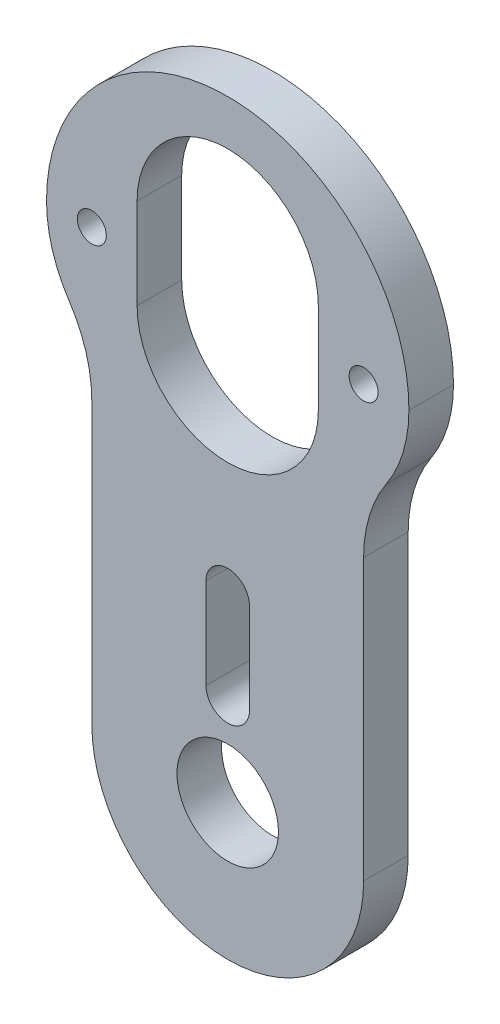
from build123d import *

# Parameters (mm, degrees)
CROQUIS1_R              = 3.556
SALIENTE_EXTRUIR1_DEPTH = 3.1242
SALIENTE_EXTRUIR3_START = -3.1242
SALIENTE_EXTRUIR3_DEPTH = 3.1242
CROQUIS3_R              = 1.016
CORTAR_EXTRUIR1_DEPTH   = 45.81344142


with BuildPart() as part:
    # Croquis1 → Saliente-Extruir1 (new body)
    with BuildSketch(Plane.XY):
        with BuildLine():
            Line((9.525, 0), (9.525, 33.3375))
            ThreePointArc((9.525, 33.3375), (0, 42.8625), (-9.525, 33.3375))
            Line((-9.525, 33.3375), (-9.525, 0))
            ThreePointArc((-9.525, 0), (0, -9.525), (9.525, 0))
        make_face()
        Circle(CROQUIS1_R, mode=Mode.SUBTRACT)
        with BuildLine():
            ThreePointArc((-6.35, 26.9875), (0, 20.6375), (6.35, 26.9875))
            Line((6.35, 26.9875), (6.35, 33.3375))
            ThreePointArc((6.35, 33.3375), (0, 39.6875), (-6.35, 33.3375))
            Line((-6.35, 33.3375), (-6.35, 26.9875))
        make_face(mode=Mode.SUBTRACT)
        with BuildLine():
            ThreePointArc((1.524, 12.7), (0, 14.224), (-1.524, 12.7))
            Line((-1.524, 12.7), (-1.524, 6.35))
            ThreePointArc((-1.524, 6.35), (0, 4.826), (1.524, 6.35))
            Line((1.524, 6.35), (1.524, 12.7))
        make_face(mode=Mode.SUBTRACT)
    extrude(amount=SALIENTE_EXTRUIR1_DEPTH)

    # Croquis2 → Saliente-Extruir3 (add)
    with BuildSketch(Plane.XY.offset(3.1242).offset(SALIENTE_EXTRUIR3_START)):
        with BuildLine():
            ThreePointArc((-9.525, 33.3375), (-6.735192091, 40.072692091), (0, 42.8625))
            ThreePointArc((0, 42.8625), (-8.980256121, 39.142756121), (-12.7, 30.1625))
            ThreePointArc((-12.7, 30.1625), (-12.294493201, 27.412869343), (-11.1125, 24.897358145))
            ThreePointArc((-11.1125, 24.897358145), (-9.930506799, 22.381846948), (-9.525, 19.632216291))
            Line((-9.525, 19.632216291), (-9.525, 29.1465))
            ThreePointArc((-9.525, 29.1465), (-10.541, 30.1625), (-9.525, 31.1785))
            Line((-9.525, 31.1785), (-9.525, 33.3375))
        make_face()
        with BuildLine():
            ThreePointArc((12.7, 30.1625), (8.980256121, 39.142756121), (0, 42.8625))
            ThreePointArc((0, 42.8625), (6.735192091, 40.072692091), (9.525, 33.3375))
            Line((9.525, 33.3375), (9.525, 31.1785))
            ThreePointArc((9.525, 31.1785), (10.541, 30.1625), (9.525, 29.1465))
            Line((9.525, 29.1465), (9.525, 19.632216291))
            ThreePointArc((9.525, 19.632216291), (9.930506799, 22.381846948), (11.1125, 24.897358145))
            ThreePointArc((11.1125, 24.897358145), (12.294493201, 27.412869343), (12.7, 30.1625))
        make_face()
    extrude(amount=SALIENTE_EXTRUIR3_DEPTH)

    # Croquis3 → Cortar-Extruir1 (cut, through all)
    with BuildSketch(Plane.XY.offset(3.1242)):
        with Locations((-9.525, 30.1625)):
            Circle(CROQUIS3_R)
        with Locations((9.525, 30.1625)):
            Circle(CROQUIS3_R)
    extrude(amount=-CORTAR_EXTRUIR1_DEPTH, mode=Mode.SUBTRACT)


solid = part.part
